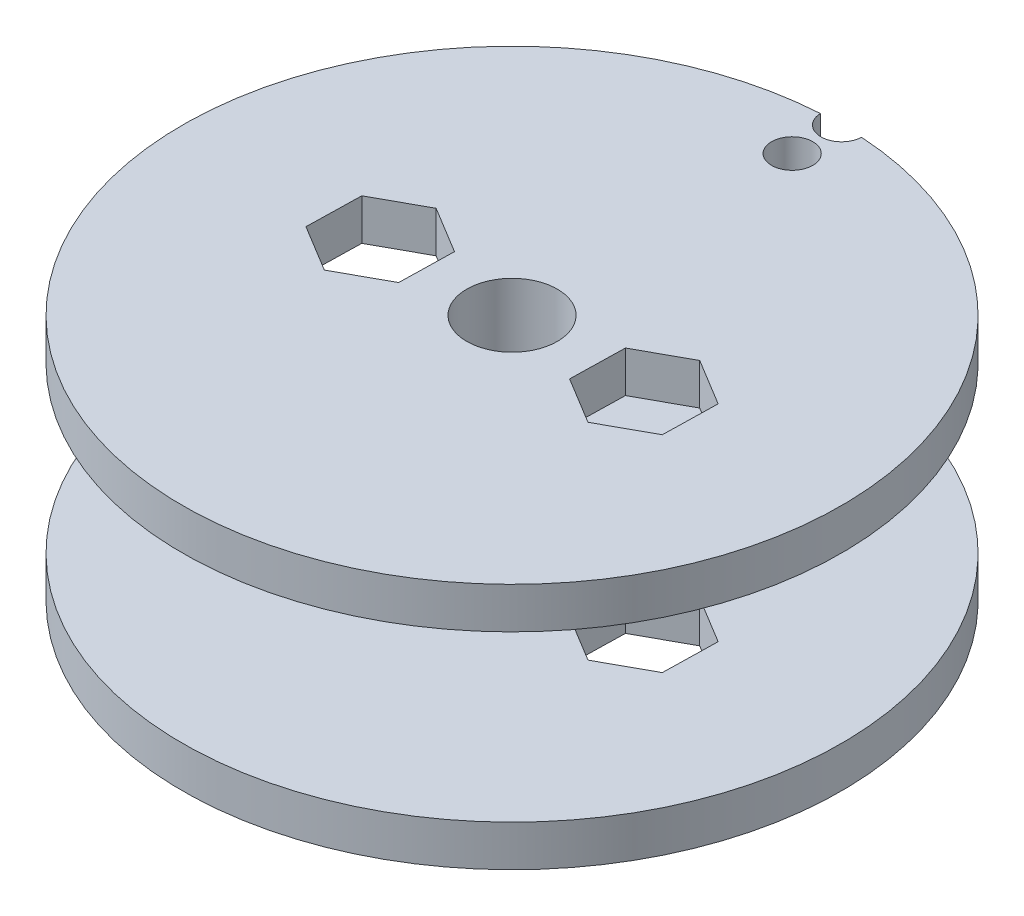
from build123d import *

# Parameters (mm, degrees)
SKETCH1_R           = 20
SKETCH1_R_2         = 2.75
BOSS_EXTRUDE1_DEPTH = 2.5
CUT_EXTRUDE3_DEPTH  = 2.5
SKETCH4_R           = 1.25
CUT_EXTRUDE4_DEPTH  = 5
SKETCH2_R           = 3
SKETCH2_R_2         = 2.75
BOSS_EXTRUDE2_DEPTH = 5


with BuildPart() as part:
    # Sketch1 → Boss-Extrude1 (new body)
    with BuildSketch(Plane(origin=(0, 0, 0), x_dir=(1, 0, 0), z_dir=(0, 1, 0))):
        Circle(SKETCH1_R)
        Circle(SKETCH1_R_2, mode=Mode.SUBTRACT)
    extrude(amount=BOSS_EXTRUDE1_DEPTH)

    # Sketch3 → Cut-Extrude3 (cut)
    with BuildSketch(Plane.XZ):
        Polygon((-5.161329605, 1.721273866), (-8.071331697, 3.318997608), (-10.910002092, 1.597723742), (-10.838670395, -1.721273866), (-7.928668303, -3.318997608), (-5.089997908, -1.597723742), align=None)
        Polygon((5.161329605, -1.721273866), (8.071331697, -3.318997608), (10.910002092, -1.597723742), (10.838670395, 1.721273866), (7.928668303, 3.318997608), (5.089997908, 1.597723742), align=None)
    extrude(amount=-CUT_EXTRUDE3_DEPTH, mode=Mode.SUBTRACT)

    # Sketch4 → Cut-Extrude4 (cut)
    with BuildSketch(Plane(origin=(0, 2.5, 0), x_dir=(1, 0, 0), z_dir=(0, 1, 0))):
        with Locations((0, 17)):
            Circle(SKETCH4_R)
        with Locations((0, 20)):
            Circle(SKETCH4_R)
    extrude(amount=-CUT_EXTRUDE4_DEPTH, mode=Mode.SUBTRACT)

    # Sketch2 → Boss-Extrude2 (add)
    with BuildSketch(Plane(origin=(0, 2.5, 0), x_dir=(1, 0, 0), z_dir=(0, 1, 0))):
        Circle(SKETCH2_R)
        Circle(SKETCH2_R_2, mode=Mode.SUBTRACT)
    extrude(amount=BOSS_EXTRUDE2_DEPTH)

    # Mirror7: part across plane


with BuildPart() as part_1:
    add(part.part)
    add(part.part.mirror(Plane.ZX.offset(7.5)))


solid = part_1.part
